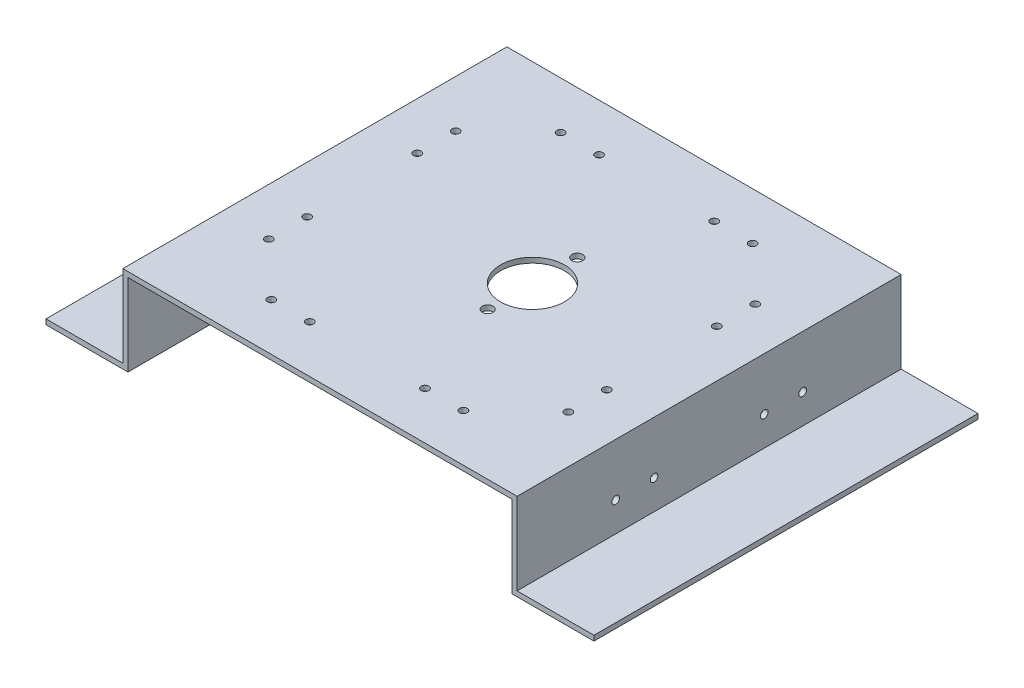
from build123d import *

# Parameters (mm, degrees)
BOSS_EXTRUDE1_DEPTH       = 150
CUT_EXTRUDE1_REACH        = 36
SKETCH2_R                 = 12.5
CUT_EXTRUDE2_REACH        = 36
SKETCH3_R                 = 2.1
F_3_0MM_DOWEL_HOLE1_D     = 3
F_3_0MM_DOWEL_HOLE1_DEPTH = 2
F_3_0MM_DOWEL_HOLE2_D     = 3
F_3_0MM_DOWEL_HOLE2_DEPTH = 2.001


with BuildPart() as part:
    # Sketch1 → Boss-Extrude1 (new body)
    with BuildSketch(Plane.XY):
        Polygon((-77, 17), (77, 17), (77, -15), (107, -15), (107, -17), (75, -17), (75, 15), (-75, 15), (-75, -17), (-107, -17), (-107, -15), (-77, -15), align=None)
    extrude(amount=BOSS_EXTRUDE1_DEPTH)

    # Sketch2 → Cut-Extrude1 (cut, up to next)
    with BuildSketch(Plane(origin=(0, 17, 0), x_dir=(1, 0, 0), z_dir=(0, 1, 0)), mode=Mode.PRIVATE) as cut_extrude1_sk1:
        with Locations((8, -75)):
            Circle(SKETCH2_R)
    cut_extrude1_tool1 = extrude(cut_extrude1_sk1.sketch, amount=-CUT_EXTRUDE1_REACH, mode=Mode.PRIVATE) & part.part
    add(cut_extrude1_tool1.solids().sort_by_distance((8, 17, 75))[0], mode=Mode.SUBTRACT)

    # Sketch3 → Cut-Extrude2 (cut, up to next)
    with BuildSketch(Plane(origin=(0, 17, 0), x_dir=(1, 0, 0), z_dir=(0, 1, 0)), mode=Mode.PRIVATE) as cut_extrude2_sk1:
        with Locations((8, -57.5)):
            Circle(SKETCH3_R)
    cut_extrude2_tool1 = extrude(cut_extrude2_sk1.sketch, amount=-CUT_EXTRUDE2_REACH, mode=Mode.PRIVATE) & part.part
    add(cut_extrude2_tool1.solids().sort_by_distance((8, 17, 57.5))[0], mode=Mode.SUBTRACT)
    # Sketch3 → Cut-Extrude2 (cut, up to next)
    with BuildSketch(Plane(origin=(0, 17, 0), x_dir=(1, 0, 0), z_dir=(0, 1, 0)), mode=Mode.PRIVATE) as cut_extrude2_sk2:
        with Locations((8, -92.5)):
            Circle(SKETCH3_R)
    cut_extrude2_tool2 = extrude(cut_extrude2_sk2.sketch, amount=-CUT_EXTRUDE2_REACH, mode=Mode.PRIVATE) & part.part
    add(cut_extrude2_tool2.solids().sort_by_distance((8, 17, 92.5))[0], mode=Mode.SUBTRACT)

    # Ø3.0mm Dowel Hole1
    with Locations(Plane(origin=(0, 15, 0), x_dir=(-1, 0, 0), z_dir=(0, -1, 0))):
        with Locations((58.5, -111.5), (58.5, -96.5), (37.5, -131.5), (22.5, -131.5), (-22.5, -131.5), (-37.5, -131.5), (-58.5, -111.5), (-58.5, -96.5), (-58.5, -53.5), (-58.5, -38.5), (-37.5, -18.5), (-22.5, -18.5), (22.5, -18.5), (37.5, -18.5), (58.5, -53.5), (58.5, -38.5)):
            Hole(F_3_0MM_DOWEL_HOLE1_D / 2, depth=F_3_0MM_DOWEL_HOLE1_DEPTH)

    # Ø3.0mm Dowel Hole2
    with Locations(Plane.ZY.offset(-75)):
        with Locations((38.5, -3.5), (53.5, -3.5), (96.5, -3.5), (111.5, -3.5)):
            f_3_0mm_dowel_hole2 = Hole(F_3_0MM_DOWEL_HOLE2_D / 2, depth=F_3_0MM_DOWEL_HOLE2_DEPTH)

    # Mirror1: Ø3.0mm Dowel Hole2 across plane
    add(f_3_0mm_dowel_hole2.mirror(Plane(origin=(0, 0, 0), x_dir=(0, 0, 1), z_dir=(1, 0, 0))), mode=Mode.SUBTRACT)


solid = part.part
